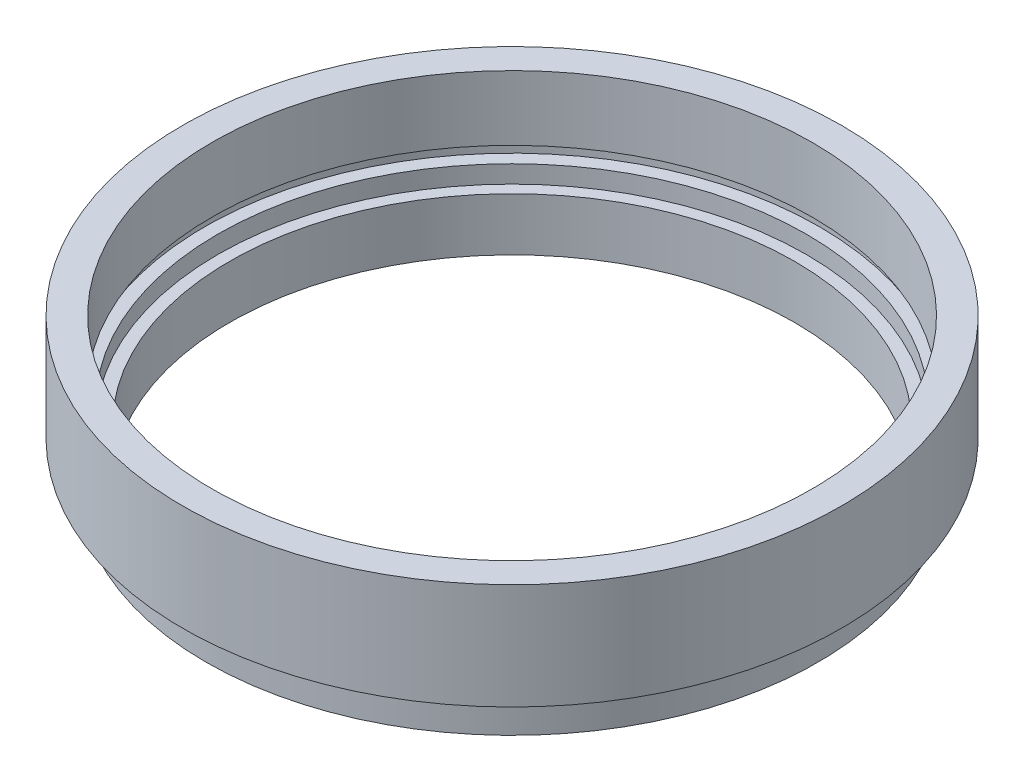
from build123d import *


with BuildPart() as part:
    # 草图1 → 旋转1 (revolve)
    with BuildSketch(Plane.XY, mode=Mode.PRIVATE) as revolve_1_sk:
        Polygon((24, 0), (26, 0), (26, 2.5), (25.5, 2.5), (25.5, 3.5), (28, 3.5), (28, 12.5), (25.5, 12.5), (25.5, 7), (26.1, 7), (26.1, 6), (25, 6), (25, 4.5), (24, 4.5), align=None)
    revolve(revolve_1_sk.sketch.rotate(Axis((0, 0, 0), (0, 1, 0)), 90), axis=Axis((0, 0, 0), (0, 1, 0)))  # turned: the seam where the file's is


solid = part.part
